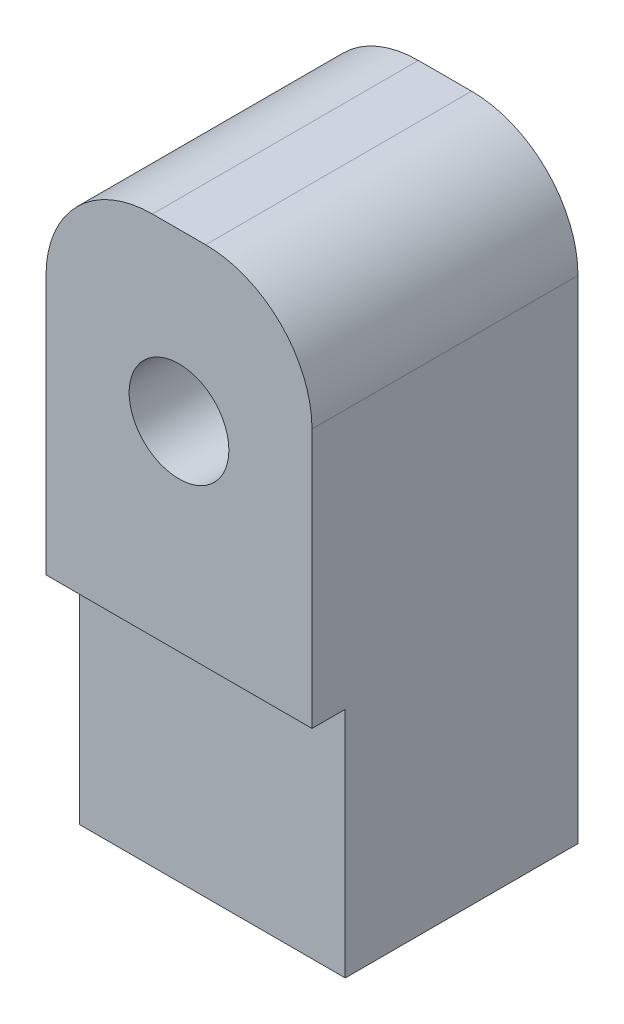
from build123d import *

# Parameters (mm, degrees)
SKETCH2_W           = 10
SKETCH2_H           = 8.75
BOSS_EXTRUDE1_DEPTH = 8.75
SKETCH3_W           = 10
SKETCH3_H           = 10
BOSS_EXTRUDE2_DEPTH = 13.75
FILLET1_R           = 4
SKETCH4_R           = 2.5
CUT_EXTRUDE1_DEPTH  = 11.88
SKETCH5_R           = 1.875
CUT_EXTRUDE2_DEPTH  = 8.75
SKETCH6_R           = 2.375
CUT_EXTRUDE3_DEPTH  = 1.25


with BuildPart() as part:
    # Sketch2 → Boss-Extrude1 (new body)
    with BuildSketch(Plane.XY):
        with Locations((0, -6.875)):
            Rectangle(SKETCH2_W, SKETCH2_H)
    extrude(amount=BOSS_EXTRUDE1_DEPTH)

    # Sketch3 → Boss-Extrude2 (add)
    with BuildSketch(Plane(origin=(0, -2.5, 0), x_dir=(1, 0, 0), z_dir=(0, 1, 0))):
        with Locations((0, -5)):
            Rectangle(SKETCH3_W, SKETCH3_H)
    extrude(amount=BOSS_EXTRUDE2_DEPTH)

    # Fillet1
    fillet1_edges = [part.edges().sort_by_distance(p)[0] for p in [
        (5, 11.25, 5),
        (-5, 11.25, 5),
    ]]
    fillet(fillet1_edges, radius=FILLET1_R)

    # Sketch4 → Cut-Extrude1 (cut)
    with BuildSketch(Plane.XZ.offset(11.25)):
        with Locations((0, 5)):
            Circle(SKETCH4_R)
    extrude(amount=-CUT_EXTRUDE1_DEPTH, mode=Mode.SUBTRACT)

    # Sketch5 → Cut-Extrude2 (cut)
    with BuildSketch(Plane.XY.offset(10)):
        with Locations((0, 5)):
            Circle(SKETCH5_R)
    extrude(amount=-CUT_EXTRUDE2_DEPTH, mode=Mode.SUBTRACT)

    # Sketch6 → Cut-Extrude3 (cut)
    with BuildSketch(Plane(origin=(0, 0, 0), x_dir=(-1, 0, 0), z_dir=(0, 0, -1))):
        with Locations((0, 5)):
            Circle(SKETCH6_R)
    extrude(amount=-CUT_EXTRUDE3_DEPTH, mode=Mode.SUBTRACT)


solid = part.part
